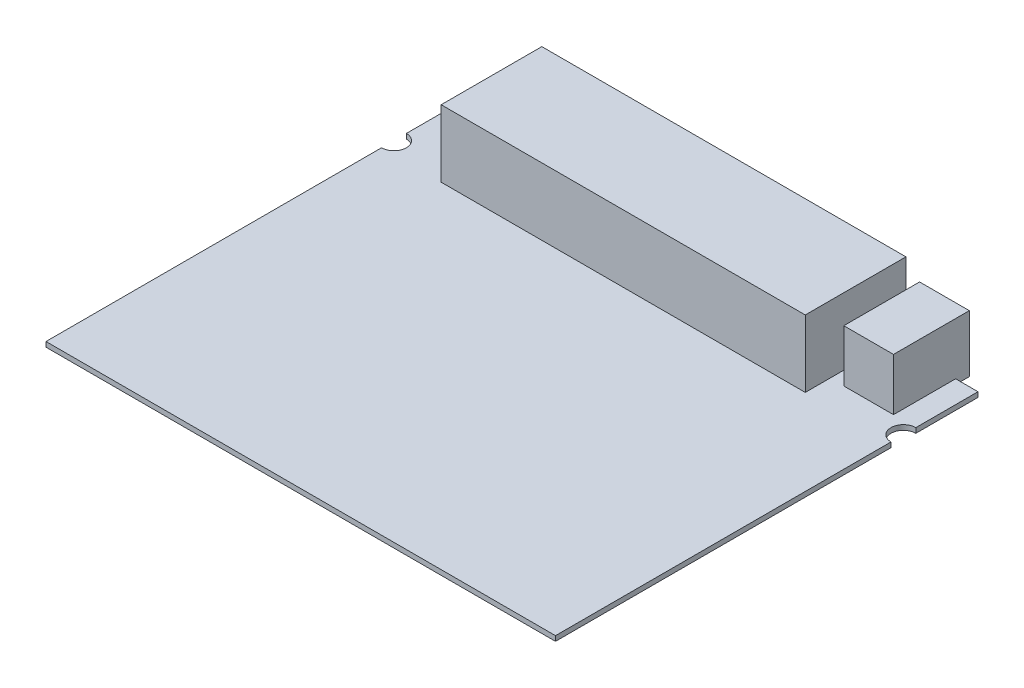
from build123d import *

# Parameters (mm, degrees)
SKETCH2_W           = 74.422
SKETCH2_H           = 20.574
BOSS_EXTRUDE3_DEPTH = 14.732
SKETCH7_W           = 10.16
SKETCH7_H           = 15.494
BOSS_EXTRUDE4_DEPTH = 11.684
BOSS_EXTRUDE5_DEPTH = 1.016


with BuildPart() as part:
    # Sketch2 → Boss-Extrude3 (new body)
    with BuildSketch(Plane(origin=(0, 0, 0), x_dir=(1, 0, 0), z_dir=(0, 1, 0))):
        with Locations((-2.667, 35.687)):
            Rectangle(SKETCH2_W, SKETCH2_H)
    extrude(amount=BOSS_EXTRUDE3_DEPTH)



with BuildPart() as body_2:
    # Sketch7 → Boss-Extrude4 (new body)
    with BuildSketch(Plane(origin=(0, 0, 0), x_dir=(1, 0, 0), z_dir=(0, 1, 0))):
        with Locations((42.418, 38.227)):
            Rectangle(SKETCH7_W, SKETCH7_H)
    extrude(amount=BOSS_EXTRUDE4_DEPTH)


with BuildPart() as part_1:
    add(part.part)

    add(body_2.part)  # Boss-Extrude5 merges body 2
    # Sketch9 → Boss-Extrude5 (add)
    with BuildSketch(Plane(origin=(0, 0, 0), x_dir=(1, 0, 0), z_dir=(0, 1, 0))):
        with BuildLine():
            Line((-39.878, 43.18), (-52.07, 43.18))
            Line((-52.07, 43.18), (-52.07, 30.48))
            ThreePointArc((-52.07, 30.48), (-49.53, 27.94), (-52.07, 25.4))
            Line((-52.07, 25.4), (-52.07, -43.18))
            Line((-52.07, -43.18), (52.07, -43.18))
            Line((52.07, -43.18), (52.07, 25.4))
            ThreePointArc((52.07, 25.4), (49.53, 27.94), (52.07, 30.48))
            Line((52.07, 30.48), (52.07, 43.18))
            Line((52.07, 43.18), (47.498, 43.18))
            Line((47.498, 43.18), (47.498, 30.48))
            Line((47.498, 30.48), (37.338, 30.48))
            Line((37.338, 30.48), (37.338, 43.18))
            Line((37.338, 43.18), (34.544, 43.18))
            Line((34.544, 43.18), (34.544, 25.4))
            Line((34.544, 25.4), (-39.878, 25.4))
            Line((-39.878, 25.4), (-39.878, 43.18))
        make_face()
    extrude(amount=BOSS_EXTRUDE5_DEPTH)


solid = part_1.part
